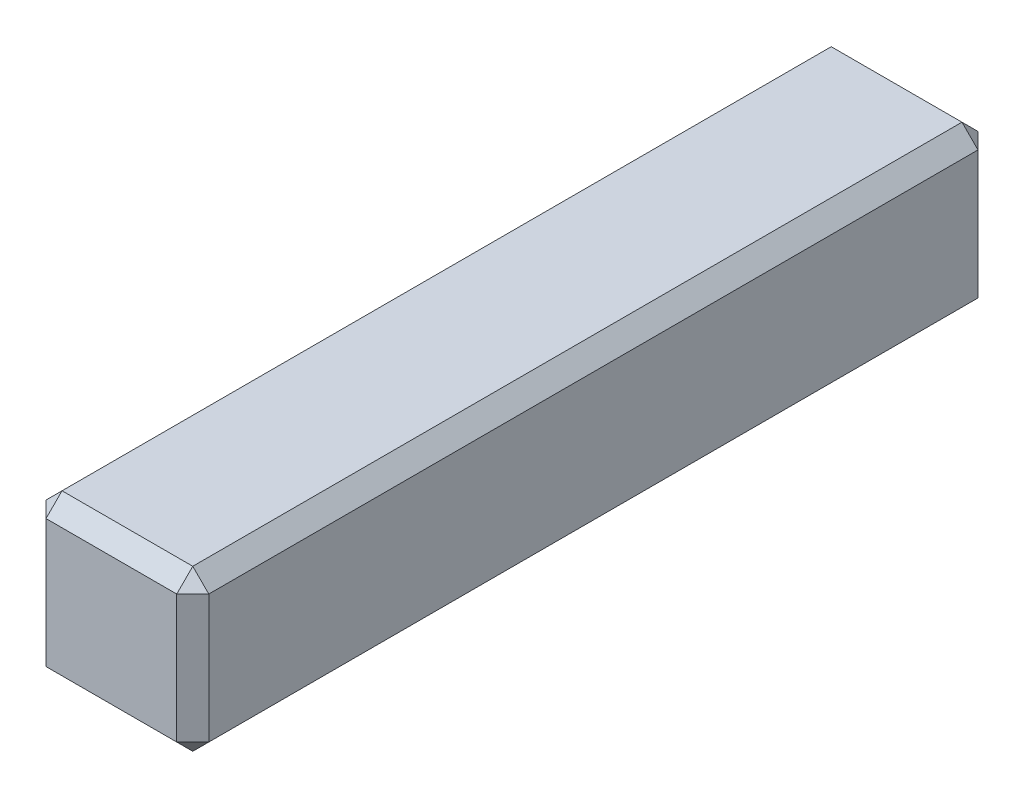
from build123d import *

# Parameters (mm, degrees)
SKETCH1_W           = 2.031754164
SKETCH1_H           = 2
BOSS_EXTRUDE1_DEPTH = 5
CHAMFER1_SIZE       = 0.2


with BuildPart() as part:
    # Sketch1 → Boss-Extrude1 (new body, symmetric)
    with BuildSketch(Plane.XY):
        with Locations((-50.205131276, 12.553058878)):
            Rectangle(SKETCH1_W, SKETCH1_H)
    extrude(amount=BOSS_EXTRUDE1_DEPTH, both=True)

    # Chamfer1
    chamfer1_edges = [part.edges().sort_by_distance(p)[0] for p in [
        (-50.205131276, 11.553058878, 5),
        (-49.189254194, 12.553058878, 5),
        (-50.205131276, 13.553058878, 5),
        (-49.189254194, 12.553058878, -5),
        (-50.205131276, 11.553058878, -5),
        (-51.221008358, 12.553058878, -5),
        (-50.205131276, 13.553058878, -5),
        (-51.221008358, 12.553058878, 5),
        (-49.189254194, 13.553058878, 0),
        (-49.189254194, 11.553058878, 0),
        (-51.221008358, 11.553058878, 0),
        (-51.221008358, 13.553058878, 0),
    ]]
    chamfer(chamfer1_edges, length=CHAMFER1_SIZE)


solid = part.part
